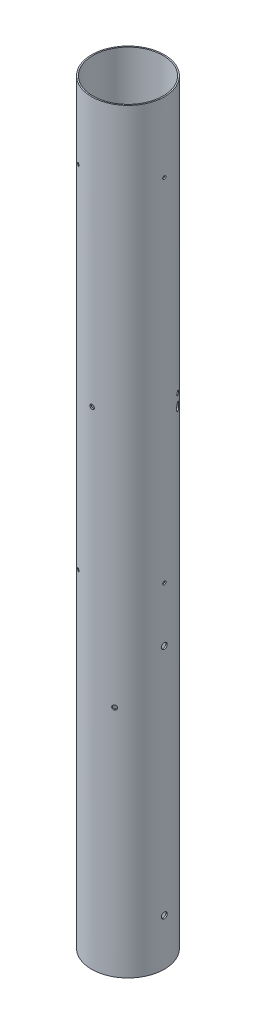
from build123d import *

# Parameters (mm, degrees)
SKETCH1_R                             = 39.624
SKETCH1_R_2                           = 38.227
BOSS_EXTRUDE1_DEPTH                   = 822.5282
S1A_COUPLER_REACH                     = 829.981
SKETCH2_R                             = 1.778
S1A_COUPLER_PATTERN_COUNT             = 3
S1A_RAIL_GUIDE_REACH                  = 829.286
SKETCH3_R                             = 3.175
S1A_PRESSURE_REACH                    = 829.971
SKETCH4_R                             = 2.38125
S1A_PRESSURE_PATTERN_COUNT            = 3
SWITCH_SLOT_REACH                     = 829.99
S1A_PRESSURE_2_REACH                  = 829.981
SKETCH7_R                             = 2.38125
S1A_PRESSURE_2_PATTERN_COUNT          = 3
S1B_PROPULSION_BULKHEAD_REACH         = 829.981
SKETCH8_R                             = 1.7859375
S1B_PROPULSION_BULKHEAD_PATTERN_COUNT = 3


with BuildPart() as part:
    # Sketch1 → Boss-Extrude1 (new body)
    with BuildSketch(Plane(origin=(0, 0, 0), x_dir=(1, 0, 0), z_dir=(0, 1, 0))):
        Circle(SKETCH1_R)
        Circle(SKETCH1_R_2, mode=Mode.SUBTRACT)
    extrude(amount=BOSS_EXTRUDE1_DEPTH)

    # Sketch2 → S1A_Coupler (cut, up to next)
    with BuildSketch(Plane(origin=(-19.812, 0, 34.3153906), x_dir=(0, -1, 0), z_dir=(-0.499999999999998, 0, 0.8660254037844398)), mode=Mode.PRIVATE) as s1a_coupler_sk1:
        with Locations((-746.3282, 0)):
            Circle(SKETCH2_R)
    s1a_coupler_tool1 = extrude(s1a_coupler_sk1.sketch, amount=-S1A_COUPLER_REACH, mode=Mode.PRIVATE) & part.part
    s1a_coupler = s1a_coupler_tool1.solids().sort_by_distance((-19.812, 746.3282, 34.315391))[0]
    add(s1a_coupler, mode=Mode.SUBTRACT)

    # S1A_Coupler_Pattern: S1A_Coupler ×3 about axis
    s1a_coupler_pattern_axis = Axis((0, -40.64, 0), (0, 1, 0))
    for i in range(1, S1A_COUPLER_PATTERN_COUNT):
        add(s1a_coupler.rotate(s1a_coupler_pattern_axis, i * 360 / S1A_COUPLER_PATTERN_COUNT), mode=Mode.SUBTRACT)

    # Sketch3 → S1A_Rail_Guide (cut, up to next)
    with BuildSketch(Plane(origin=(39.624, 0, 0), x_dir=(0, 0, -1), z_dir=(1, 0, 0)), mode=Mode.PRIVATE) as s1a_rail_guide_sk1:
        with Locations((0, 50.8)):
            Circle(SKETCH3_R)
    s1a_rail_guide_tool1 = extrude(s1a_rail_guide_sk1.sketch, amount=-S1A_RAIL_GUIDE_REACH, mode=Mode.PRIVATE) & part.part
    # Sketch3 → S1A_Rail_Guide (cut, up to next)
    with BuildSketch(Plane(origin=(39.624, 0, 0), x_dir=(0, 0, -1), z_dir=(1, 0, 0)), mode=Mode.PRIVATE) as s1a_rail_guide_sk2:
        with Locations((0, 304.8)):
            Circle(SKETCH3_R)
    s1a_rail_guide_tool2 = extrude(s1a_rail_guide_sk2.sketch, amount=-S1A_RAIL_GUIDE_REACH, mode=Mode.PRIVATE) & part.part
    add(s1a_rail_guide_tool1.solids().sort_by_distance((39.624, 50.8, 0))[0], mode=Mode.SUBTRACT)
    add(s1a_rail_guide_tool2.solids().sort_by_distance((39.624, 304.8, 0))[0], mode=Mode.SUBTRACT)

    # Sketch4 → S1A_Pressure (cut, up to next)
    with BuildSketch(Plane(origin=(-34.59203775, 0, -19.324913979), x_dir=(0, -1, 0), z_dir=(-0.8730072115474079, 0, -0.48770729806536567)), mode=Mode.PRIVATE) as s1a_pressure_sk1:
        with Locations((-530.4282, 0)):
            Circle(SKETCH4_R)
    s1a_pressure_tool1 = extrude(s1a_pressure_sk1.sketch, amount=-S1A_PRESSURE_REACH, mode=Mode.PRIVATE) & part.part
    s1a_pressure = s1a_pressure_tool1.solids().sort_by_distance((-34.592038, 530.4282, -19.324914))[0]
    add(s1a_pressure, mode=Mode.SUBTRACT)

    # S1A_Pressure_Pattern: S1A_Pressure ×3 about axis
    s1a_pressure_pattern_axis = Axis((0, -40.64, 0), (0, 1, 0))
    for i in range(1, S1A_PRESSURE_PATTERN_COUNT):
        add(s1a_pressure.rotate(s1a_pressure_pattern_axis, i * 360 / S1A_PRESSURE_PATTERN_COUNT), mode=Mode.SUBTRACT)

    # Sketch6 → Switch_Slot (cut, up to next)
    with BuildSketch(Plane(origin=(34.031885307, 0, -20.295126471), x_dir=(0, -1, 0), z_dir=(0.8588705155093787, 0, -0.5121927738543899)), mode=Mode.PRIVATE) as switch_slot_sk1:
        with BuildLine():
            Line((-518.9982, 3.175), (-516.4582, 3.175))
            ThreePointArc((-516.4582, 3.175), (-513.2832, 0), (-516.4582, -3.175))
            Line((-516.4582, -3.175), (-518.9982, -3.175))
            ThreePointArc((-518.9982, -3.175), (-522.1732, 0), (-518.9982, 3.175))
        make_face()
    switch_slot_tool1 = extrude(switch_slot_sk1.sketch, amount=-SWITCH_SLOT_REACH, mode=Mode.PRIVATE) & part.part
    add(switch_slot_tool1.solids().sort_by_distance((34.031885, 517.7282, -20.295126))[0], mode=Mode.SUBTRACT)

    # Sketch7 → S1A_Pressure_2 (cut, up to next)
    with BuildSketch(Plane(origin=(19.812, 0, 34.3153906), x_dir=(0, -1, 0), z_dir=(0.499999999999998, 0, 0.8660254037844398)), mode=Mode.PRIVATE) as s1a_pressure_2_sk1:
        with Locations((-254, 0)):
            Circle(SKETCH7_R)
    s1a_pressure_2_tool1 = extrude(s1a_pressure_2_sk1.sketch, amount=-S1A_PRESSURE_2_REACH, mode=Mode.PRIVATE) & part.part
    s1a_pressure_2 = s1a_pressure_2_tool1.solids().sort_by_distance((19.812, 254, 34.315391))[0]
    add(s1a_pressure_2, mode=Mode.SUBTRACT)

    # S1A_Pressure_2_Pattern: S1A_Pressure_2 ×3 about axis
    s1a_pressure_2_pattern_axis = Axis((0, -40.64, 0), (0, 1, 0))
    for i in range(1, S1A_PRESSURE_2_PATTERN_COUNT):
        add(s1a_pressure_2.rotate(s1a_pressure_2_pattern_axis, i * 360 / S1A_PRESSURE_2_PATTERN_COUNT), mode=Mode.SUBTRACT)

    # Sketch8 → S1B_Propulsion_Bulkhead (cut, up to next)
    with BuildSketch(Plane(origin=(-19.812, 0, 34.3153906), x_dir=(0, -1, 0), z_dir=(-0.499999999999998, 0, 0.8660254037844398)), mode=Mode.PRIVATE) as s1b_propulsion_bulkhead_sk1:
        with Locations((-364.1217, 0)):
            Circle(SKETCH8_R)
    s1b_propulsion_bulkhead_tool1 = extrude(s1b_propulsion_bulkhead_sk1.sketch, amount=-S1B_PROPULSION_BULKHEAD_REACH, mode=Mode.PRIVATE) & part.part
    s1b_propulsion_bulkhead = s1b_propulsion_bulkhead_tool1.solids().sort_by_distance((-19.812, 364.1217, 34.315391))[0]
    add(s1b_propulsion_bulkhead, mode=Mode.SUBTRACT)

    # S1B_Propulsion_Bulkhead_Pattern: S1B_Propulsion_Bulkhead ×3 about axis
    s1b_propulsion_bulkhead_pattern_axis = Axis((0, -40.64, 0), (0, 1, 0))
    for i in range(1, S1B_PROPULSION_BULKHEAD_PATTERN_COUNT):
        add(s1b_propulsion_bulkhead.rotate(s1b_propulsion_bulkhead_pattern_axis, i * 360 / S1B_PROPULSION_BULKHEAD_PATTERN_COUNT), mode=Mode.SUBTRACT)


solid = part.part
